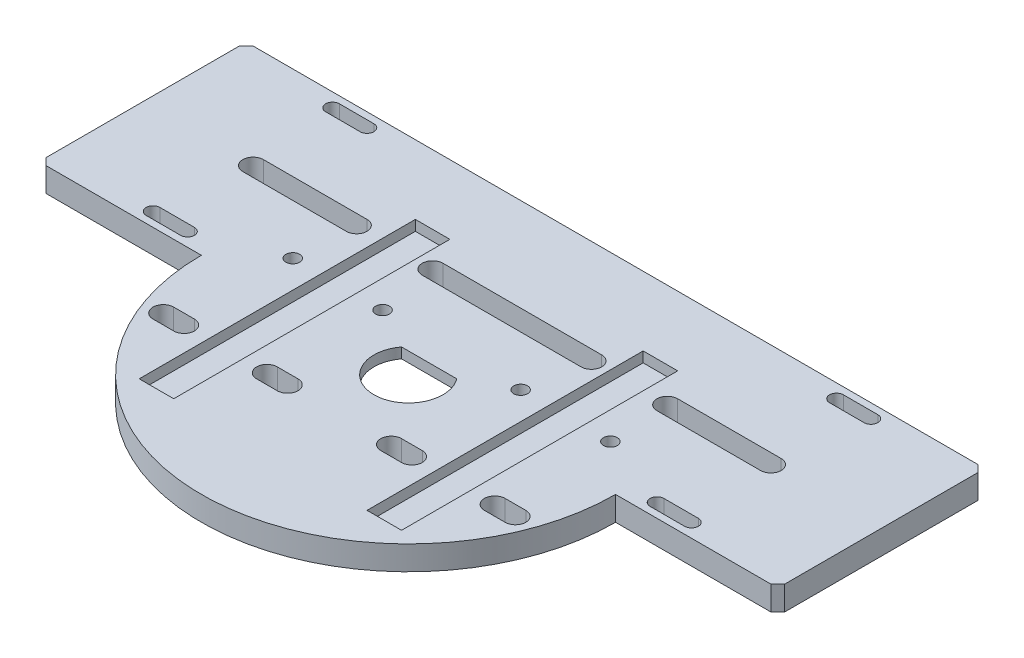
from build123d import *

# Parameters (mm, degrees)
SKETCH1_R           = 60
BOSS_EXTRUDE1_DEPTH = 7
SKETCH2_W           = 10
SKETCH2_H           = 80
BOSS_EXTRUDE2_DEPTH = 163
SKETCH8_W           = 180
SKETCH8_H           = 50
BOSS_EXTRUDE5_DEPTH = 7
CHAMFER1_SIZE       = 2
CUT_EXTRUDE3_DEPTH  = 7
CUT_EXTRUDE4_REACH  = 9
SKETCH10_R          = 10
BOSS_EXTRUDE6_DEPTH = 3
SKETCH15_W          = 10
SKETCH15_H          = 80
CUT_EXTRUDE5_DEPTH  = 166
CUT_EXTRUDE6_REACH  = 9
CUT_EXTRUDE8_REACH  = 9
CUT_EXTRUDE9_REACH  = 9
SKETCH18_R          = 2
SKETCH19_W          = 180
SKETCH19_H          = 10
SKETCH19_W_2        = 32
SKETCH19_H_2        = 7
BOSS_EXTRUDE7_DEPTH = 7
CUT_EXTRUDE10_DEPTH = 10
CHAMFER2_SIZE       = 3
SKETCH21_W          = 15
SKETCH21_H          = 0.5
SKETCH22_R          = 16
SKETCH22_R_2        = 15
BOSS_EXTRUDE8_DEPTH = 1.5
SKETCH23_W          = 20
SKETCH23_H          = 60
BOSS_EXTRUDE9_DEPTH = 7
CHAMFER3_SIZE       = 2


with BuildPart() as part:
    # Sketch1 → Boss-Extrude1 (new body)
    with BuildSketch(Plane(origin=(0, 0, 0), x_dir=(1, 0, 0), z_dir=(0, 1, 0))):
        Circle(SKETCH1_R)
    extrude(amount=-BOSS_EXTRUDE1_DEPTH)

    # Sketch2 → Boss-Extrude2 (add)
    with BuildSketch(Plane(origin=(0, 0, 0), x_dir=(1, 0, 0), z_dir=(0, 1, 0))):
        with Locations((-33, 0)):
            Rectangle(SKETCH2_W, SKETCH2_H)
        with Locations((33, 0)):
            Rectangle(SKETCH2_W, SKETCH2_H)
    extrude(amount=BOSS_EXTRUDE2_DEPTH)

    # Sketch8 → Boss-Extrude5 (add)
    with BuildSketch(Plane(origin=(0, 0, 0), x_dir=(1, 0, 0), z_dir=(0, 1, 0))):
        with Locations((0, 30)):
            Rectangle(SKETCH8_W, SKETCH8_H)
    extrude(amount=-BOSS_EXTRUDE5_DEPTH)

    # Chamfer1
    chamfer1_edges = [part.edges().sort_by_distance(p)[0] for p in [
        (90, -3.5, -5),
        (-90, -3.5, -55),
        (90, -3.5, -55),
        (-90, -3.5, -5),
    ]]
    chamfer(chamfer1_edges, length=CHAMFER1_SIZE)

    # Sketch9 → Cut-Extrude3 (cut)
    with BuildSketch(Plane(origin=(0, 0, 0), x_dir=(1, 0, 0), z_dir=(0, 1, 0))):
        with BuildLine():
            Line((45, 33), (75, 33))
            ThreePointArc((75, 33), (78, 30), (75, 27))
            Line((75, 27), (45, 27))
            ThreePointArc((45, 27), (42, 30), (45, 33))
        make_face()
    cut_extrude3 = extrude(amount=-CUT_EXTRUDE3_DEPTH, mode=Mode.SUBTRACT)

    # Mirror4: Cut-Extrude3 across plane
    add(cut_extrude3.mirror(Plane(origin=(0, 0, 0), x_dir=(0, 0, 1), z_dir=(1, 0, 0))), mode=Mode.SUBTRACT)

    # Sketch10 → Cut-Extrude4 (cut, up to next)
    with BuildSketch(Plane(origin=(0, 0, 0), x_dir=(1, 0, 0), z_dir=(0, 1, 0)), mode=Mode.PRIVATE) as cut_extrude4_sk1:
        Circle(SKETCH10_R)
    cut_extrude4_tool1 = extrude(cut_extrude4_sk1.sketch, amount=-CUT_EXTRUDE4_REACH, mode=Mode.PRIVATE) & part.part
    add(cut_extrude4_tool1.solids().sort_by_distance((0, 0, 0))[0], mode=Mode.SUBTRACT)

    # Sketch12 → Cut-Revolve1 (revolve, cut)
    with BuildSketch(Plane.XY):
        Polygon((0, -7), (0, -3.5), (-14.5, -3.5), (-14.5, -3), (-21.5, -3), (-21.5, -3.5), (-21.5, -7), align=None)
    revolve(axis=Axis((0, -7, 0), (0, 1, 0)), mode=Mode.SUBTRACT)

    # Sketch14 → Boss-Extrude6 (add)
    with BuildSketch(Plane(origin=(0, 0, 0), x_dir=(1, 0, 0), z_dir=(0, 1, 0))):
        with BuildLine():
            ThreePointArc((8, 6), (0, 10), (-8, 6))
            Line((-8, 6), (8, 6))
        make_face()
    extrude(amount=-BOSS_EXTRUDE6_DEPTH)

    # Sketch15 → Cut-Extrude5 (cut)
    with BuildSketch(Plane(origin=(0, 163, 0), x_dir=(1, 0, 0), z_dir=(0, 1, 0))):
        with Locations((33, 0)):
            Rectangle(SKETCH15_W, SKETCH15_H)
        with Locations((-33, 0)):
            Rectangle(SKETCH15_W, SKETCH15_H)
    extrude(amount=-CUT_EXTRUDE5_DEPTH, mode=Mode.SUBTRACT)

    # Sketch16 → Cut-Extrude6 (cut, up to next)
    with BuildSketch(Plane(origin=(0, 0, 0), x_dir=(1, 0, 0), z_dir=(0, 1, 0)), mode=Mode.PRIVATE) as cut_extrude6_sk1:
        with BuildLine():
            Line((-51, -17), (-45, -17))
            ThreePointArc((-45, -17), (-42, -20), (-45, -23))
            Line((-45, -23), (-51, -23))
            ThreePointArc((-51, -23), (-54, -20), (-51, -17))
        make_face()
    cut_extrude6_tool1 = extrude(cut_extrude6_sk1.sketch, amount=-CUT_EXTRUDE6_REACH, mode=Mode.PRIVATE) & part.part
    add(cut_extrude6_tool1.solids().sort_by_distance((-48, 0, 20))[0], mode=Mode.SUBTRACT)
    # Sketch16 → Cut-Extrude6 (cut, up to next)
    with BuildSketch(Plane(origin=(0, 0, 0), x_dir=(1, 0, 0), z_dir=(0, 1, 0)), mode=Mode.PRIVATE) as cut_extrude6_sk2:
        with BuildLine():
            Line((51, -17), (45, -17))
            ThreePointArc((45, -17), (42, -20), (45, -23))
            Line((45, -23), (51, -23))
            ThreePointArc((51, -23), (54, -20), (51, -17))
        make_face()
    cut_extrude6_tool2 = extrude(cut_extrude6_sk2.sketch, amount=-CUT_EXTRUDE6_REACH, mode=Mode.PRIVATE) & part.part
    add(cut_extrude6_tool2.solids().sort_by_distance((48, 0, 20))[0], mode=Mode.SUBTRACT)

    # Sketch17 → Cut-Extrude8 (cut, up to next)
    with BuildSketch(Plane(origin=(0, 0, 0), x_dir=(1, 0, 0), z_dir=(0, 1, 0)), mode=Mode.PRIVATE) as cut_extrude8_sk1:
        with BuildLine():
            Line((-23, 33), (23, 33))
            ThreePointArc((23, 33), (26, 30), (23, 27))
            Line((23, 27), (-23, 27))
            ThreePointArc((-23, 27), (-26, 30), (-23, 33))
        make_face()
    cut_extrude8_tool1 = extrude(cut_extrude8_sk1.sketch, amount=-CUT_EXTRUDE8_REACH, mode=Mode.PRIVATE) & part.part
    add(cut_extrude8_tool1.solids().sort_by_distance((0, 0, -30))[0], mode=Mode.SUBTRACT)
    # Sketch17 → Cut-Extrude8 (cut, up to next)
    with BuildSketch(Plane(origin=(0, 0, 0), x_dir=(1, 0, 0), z_dir=(0, 1, 0)), mode=Mode.PRIVATE) as cut_extrude8_sk2:
        with BuildLine():
            Line((-15, -23), (-21, -23))
            ThreePointArc((-21, -23), (-24, -20), (-21, -17))
            Line((-21, -17), (-15, -17))
            ThreePointArc((-15, -17), (-12, -20), (-15, -23))
        make_face()
    cut_extrude8_tool2 = extrude(cut_extrude8_sk2.sketch, amount=-CUT_EXTRUDE8_REACH, mode=Mode.PRIVATE) & part.part
    add(cut_extrude8_tool2.solids().sort_by_distance((-18, 0, 20))[0], mode=Mode.SUBTRACT)
    # Sketch17 → Cut-Extrude8 (cut, up to next)
    with BuildSketch(Plane(origin=(0, 0, 0), x_dir=(1, 0, 0), z_dir=(0, 1, 0)), mode=Mode.PRIVATE) as cut_extrude8_sk3:
        with BuildLine():
            Line((15, -17), (21, -17))
            ThreePointArc((21, -17), (24, -20), (21, -23))
            Line((21, -23), (15, -23))
            ThreePointArc((15, -23), (12, -20), (15, -17))
        make_face()
    cut_extrude8_tool3 = extrude(cut_extrude8_sk3.sketch, amount=-CUT_EXTRUDE8_REACH, mode=Mode.PRIVATE) & part.part
    add(cut_extrude8_tool3.solids().sort_by_distance((18, 0, 20))[0], mode=Mode.SUBTRACT)

    # Sketch18 → Cut-Extrude9 (cut, up to next)
    with BuildSketch(Plane(origin=(0, 0, 0), x_dir=(1, 0, 0), z_dir=(0, 1, 0)), mode=Mode.PRIVATE) as cut_extrude9_sk1:
        with Locations((-46, 12.5)):
            Circle(SKETCH18_R)
    cut_extrude9_tool1 = extrude(cut_extrude9_sk1.sketch, amount=-CUT_EXTRUDE9_REACH, mode=Mode.PRIVATE) & part.part
    add(cut_extrude9_tool1.solids().sort_by_distance((-46, 0, -12.5))[0], mode=Mode.SUBTRACT)
    # Sketch18 → Cut-Extrude9 (cut, up to next)
    with BuildSketch(Plane(origin=(0, 0, 0), x_dir=(1, 0, 0), z_dir=(0, 1, 0)), mode=Mode.PRIVATE) as cut_extrude9_sk2:
        with Locations((-20, 12.5)):
            Circle(SKETCH18_R)
    cut_extrude9_tool2 = extrude(cut_extrude9_sk2.sketch, amount=-CUT_EXTRUDE9_REACH, mode=Mode.PRIVATE) & part.part
    add(cut_extrude9_tool2.solids().sort_by_distance((-20, 0, -12.5))[0], mode=Mode.SUBTRACT)
    # Sketch18 → Cut-Extrude9 (cut, up to next)
    with BuildSketch(Plane(origin=(0, 0, 0), x_dir=(1, 0, 0), z_dir=(0, 1, 0)), mode=Mode.PRIVATE) as cut_extrude9_sk3:
        with Locations((20, 12.5)):
            Circle(SKETCH18_R)
    cut_extrude9_tool3 = extrude(cut_extrude9_sk3.sketch, amount=-CUT_EXTRUDE9_REACH, mode=Mode.PRIVATE) & part.part
    add(cut_extrude9_tool3.solids().sort_by_distance((20, 0, -12.5))[0], mode=Mode.SUBTRACT)
    # Sketch18 → Cut-Extrude9 (cut, up to next)
    with BuildSketch(Plane(origin=(0, 0, 0), x_dir=(1, 0, 0), z_dir=(0, 1, 0)), mode=Mode.PRIVATE) as cut_extrude9_sk4:
        with Locations((46, 12.5)):
            Circle(SKETCH18_R)
    cut_extrude9_tool4 = extrude(cut_extrude9_sk4.sketch, amount=-CUT_EXTRUDE9_REACH, mode=Mode.PRIVATE) & part.part
    add(cut_extrude9_tool4.solids().sort_by_distance((46, 0, -12.5))[0], mode=Mode.SUBTRACT)

    # Sketch19 → Boss-Extrude7 (add)
    with BuildSketch(Plane(origin=(0, 0, 0), x_dir=(1, 0, 0), z_dir=(0, 1, 0))):
        with Locations((0, 55)):
            Rectangle(SKETCH19_W, SKETCH19_H)
        with Locations((74, 3.5)):
            Rectangle(SKETCH19_W_2, SKETCH19_H_2)
        with Locations((-74, 3.5)):
            Rectangle(SKETCH19_W_2, SKETCH19_H_2)
    extrude(amount=-BOSS_EXTRUDE7_DEPTH)

    # Sketch20 → Cut-Extrude10 (cut)
    with BuildSketch(Plane(origin=(0, 0, 0), x_dir=(1, 0, 0), z_dir=(0, 1, 0))):
        with BuildLine():
            ThreePointArc((68, 2), (66, 4), (68, 6))
            Line((68, 6), (78, 6))
            ThreePointArc((78, 6), (80, 4), (78, 2))
            Line((78, 2), (68, 2))
        make_face()
        with BuildLine():
            Line((78, 58), (68, 58))
            ThreePointArc((68, 58), (66, 56), (68, 54))
            Line((68, 54), (78, 54))
            ThreePointArc((78, 54), (80, 56), (78, 58))
        make_face()
        with BuildLine():
            ThreePointArc((-68, 58), (-66, 56), (-68, 54))
            Line((-68, 54), (-78, 54))
            ThreePointArc((-78, 54), (-80, 56), (-78, 58))
            Line((-78, 58), (-68, 58))
        make_face()
        with BuildLine():
            Line((-78, 2), (-68, 2))
            ThreePointArc((-68, 2), (-66, 4), (-68, 6))
            Line((-68, 6), (-78, 6))
            ThreePointArc((-78, 6), (-80, 4), (-78, 2))
        make_face()
    extrude(amount=-CUT_EXTRUDE10_DEPTH, mode=Mode.SUBTRACT)

    # Chamfer2
    chamfer2_edges = [part.edges().sort_by_distance(p)[0] for p in [
        (-90, -3.5, -60),
        (90, -3.5, -60),
        (90, -3.5, 0),
        (-90, -3.5, 0),
    ]]
    chamfer(chamfer2_edges, length=CHAMFER2_SIZE)

    # Sketch21 → Cut-Revolve2 (revolve, cut)
    with BuildSketch(Plane(origin=(0, 0, 0), x_dir=(0, 0, -1), z_dir=(1, 0, 0))):
        with Locations((7.5, -3.25)):
            Rectangle(SKETCH21_W, SKETCH21_H)
    revolve(axis=Axis((0, 0, 0), (0, -1, 0)), mode=Mode.SUBTRACT)

    # Sketch22 → Boss-Extrude8 (add)
    with BuildSketch(Plane.XZ.offset(3)):
        Circle(SKETCH22_R)
        Circle(SKETCH22_R_2, mode=Mode.SUBTRACT)
    extrude(amount=BOSS_EXTRUDE8_DEPTH)

    # Sketch23 → Boss-Extrude9 (add)
    with BuildSketch(Plane(origin=(0, 0, 0), x_dir=(1, 0, 0), z_dir=(0, 1, 0))):
        with Locations((-97, 30)):
            Rectangle(SKETCH23_W, SKETCH23_H)
        with Locations((97, 30)):
            Rectangle(SKETCH23_W, SKETCH23_H)
    extrude(amount=-BOSS_EXTRUDE9_DEPTH)

    # Chamfer3
    chamfer3_edges = [part.edges().sort_by_distance(p)[0] for p in [
        (-107, -3.5, 0),
        (-107, -3.5, -60),
        (107, -3.5, -60),
        (107, -3.5, 0),
    ]]
    chamfer(chamfer3_edges, length=CHAMFER3_SIZE)


solid = part.part
